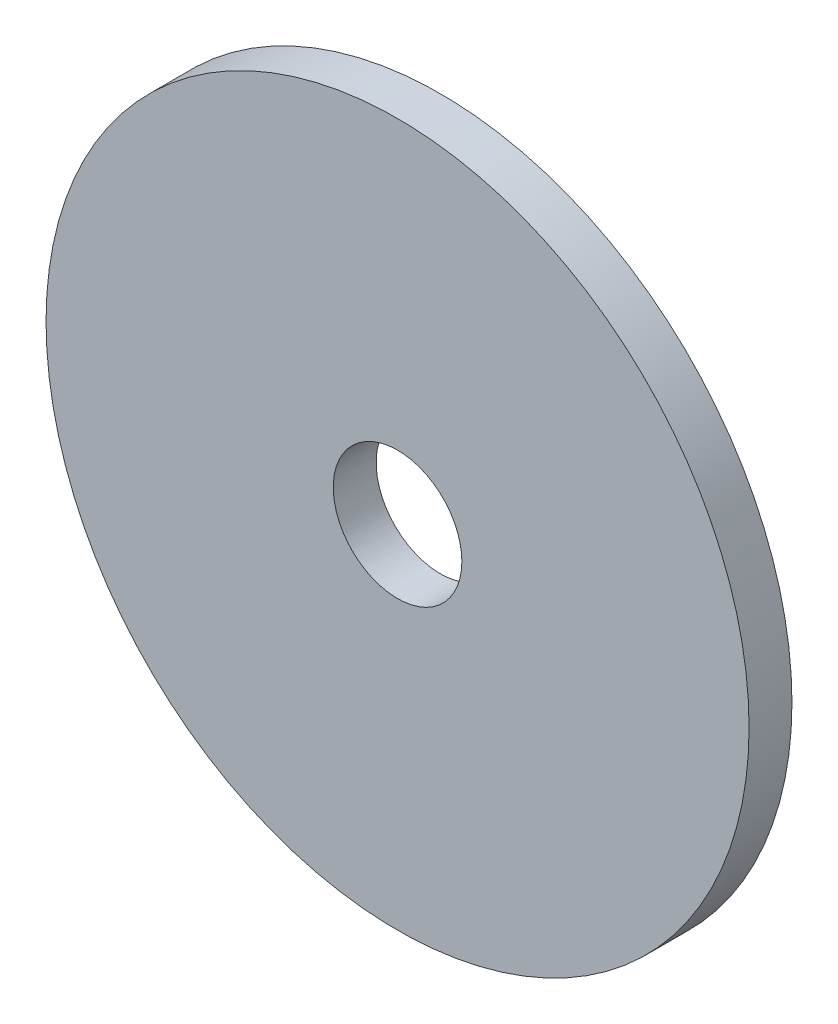
from build123d import *

# Parameters (mm, degrees)
ESQUISSE1_R             = 16.4
BOSS_EXTRU_1_DEPTH      = 2
ESQUISSE3_R             = 3
ENL_V_MAT_EXTRU_1_DEPTH = 3


with BuildPart() as part:
    # Esquisse1 → Boss.-Extru.1 (new body)
    with BuildSketch(Plane.XY):
        Circle(ESQUISSE1_R)
    extrude(amount=BOSS_EXTRU_1_DEPTH)

    # Esquisse3 → Enlèv. mat.-Extru.1 (cut, through all)
    with BuildSketch(Plane.XY.offset(2)):
        Circle(ESQUISSE3_R)
    extrude(amount=-ENL_V_MAT_EXTRU_1_DEPTH, mode=Mode.SUBTRACT)


solid = part.part
